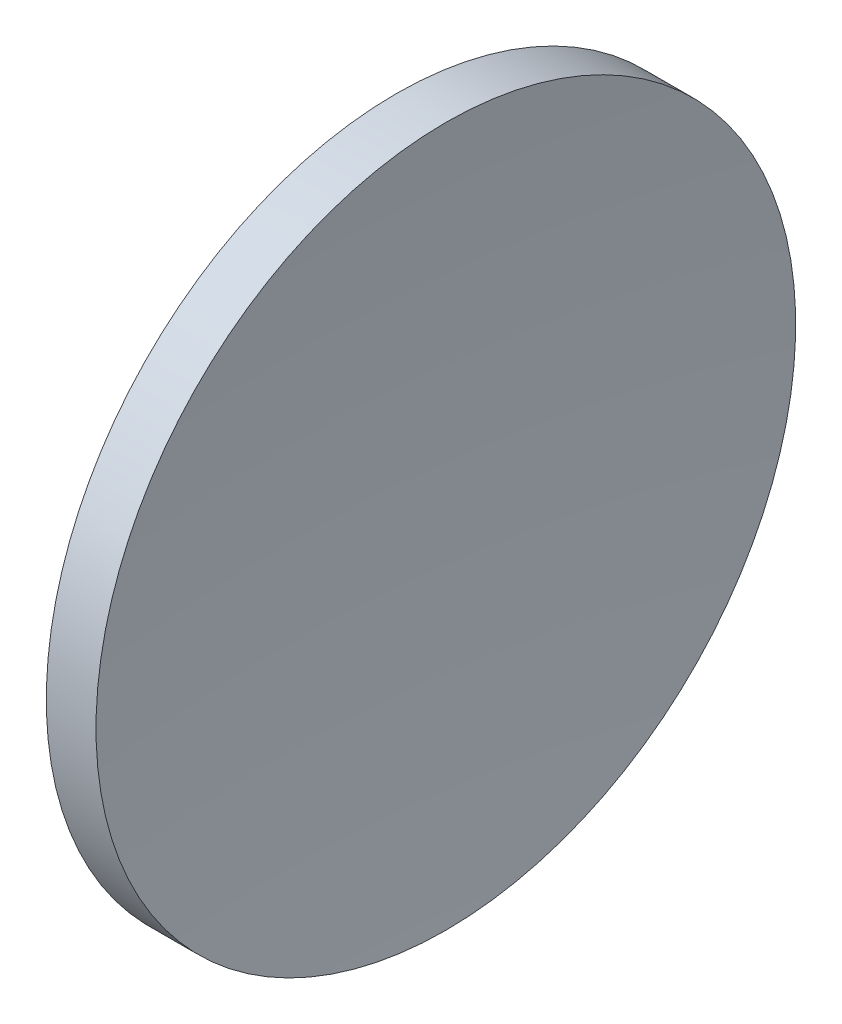
from build123d import *


with BuildPart() as part:
    # 草图1 → 旋转1 (revolve)
    with BuildSketch(Plane.XY):
        with BuildLine():
            Line((248.857134771, 155.433680942), (252.410019442, 155.433680942))
            ThreePointArc((252.410019442, 155.433680942), (251.414337017, 142.951301397), (251.082131121, 130.433680942))
            Line((251.082131121, 130.433680942), (245.282131121, 130.433680942))
            ThreePointArc((245.282131121, 130.433680942), (246.180404993, 143.060840669), (248.857134771, 155.433680942))
        make_face()
    revolve(axis=Axis((231.888982596, 130.433680942, 0), (1, 0, 0)))


solid = part.part
